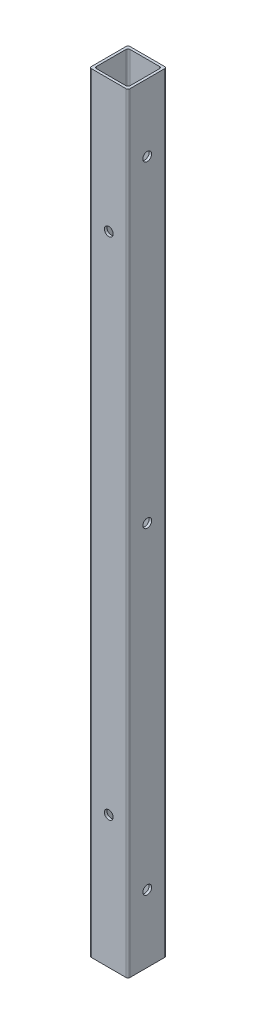
from build123d import *

# Parameters (mm, degrees)
SKETCH1_W                  = 25.4
SKETCH1_H                  = 25.4
SKETCH1_W_2                = 22.098
SKETCH1_H_2                = 22.098
BOSS_EXTRUDE1_DEPTH        = 508
FILLET1_R                  = 1.27
F_1_0_228_DIAMETER_HOLE2_D = 5.7912
F_1_0_228_DIAMETER_HOLE3_D = 5.7912


with BuildPart() as part:
    # Sketch1 → Boss-Extrude1 (new body)
    with BuildSketch(Plane(origin=(0, 0, 0), x_dir=(1, 0, 0), z_dir=(0, 1, 0))):
        Rectangle(SKETCH1_W, SKETCH1_H)
        Rectangle(SKETCH1_W_2, SKETCH1_H_2, mode=Mode.SUBTRACT)
    extrude(amount=BOSS_EXTRUDE1_DEPTH)

    # Fillet1
    fillet1_edges = [part.edges().sort_by_distance(p)[0] for p in [
        (-11.049, 254, 11.049),
        (11.049, 254, 11.049),
        (11.049, 254, -11.049),
        (-11.049, 254, -11.049),
        (12.7, 254, 12.7),
        (-12.7, 254, 12.7),
        (-12.7, 254, -12.7),
        (12.7, 254, -12.7),
    ]]
    fillet(fillet1_edges, radius=FILLET1_R)

    # #1 (0.228) Diameter Hole2 (through all)
    with Locations(Plane.ZY.offset(12.7)):
        with Locations((0, 463.55), (0, 44.45), (0, 254)):
            Hole(F_1_0_228_DIAMETER_HOLE2_D / 2)

    # #1 (0.228) Diameter Hole3 (through all)
    with Locations(Plane(origin=(0, 0, -12.7), x_dir=(-1, 0, 0), z_dir=(0, 0, -1))):
        with Locations((0, 420.6875), (0, 87.3125)):
            Hole(F_1_0_228_DIAMETER_HOLE3_D / 2)


solid = part.part
